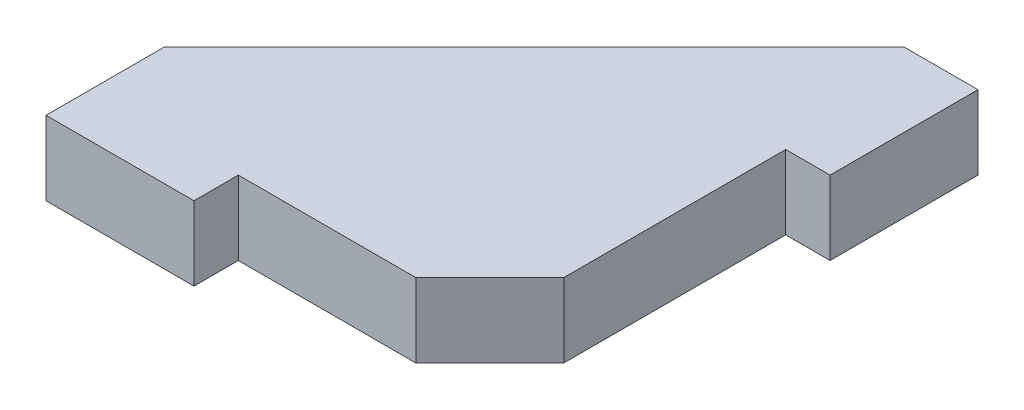
from build123d import *

# Parameters (mm, degrees)
BOSS_EXTRUDE1_DEPTH = 5


with BuildPart() as part:
    # Sketch1 → Boss-Extrude1 (new body)
    with BuildSketch(Plane(origin=(0, 0, 0), x_dir=(1, 0, 0), z_dir=(0, 1, 0))):
        Polygon((0, 0), (0, 8), (25, 33), (30, 33), (30, 23), (27, 23), (27, 8), (22, 3), (10, 3), (10, 0), align=None)
    extrude(amount=BOSS_EXTRUDE1_DEPTH)


solid = part.part
